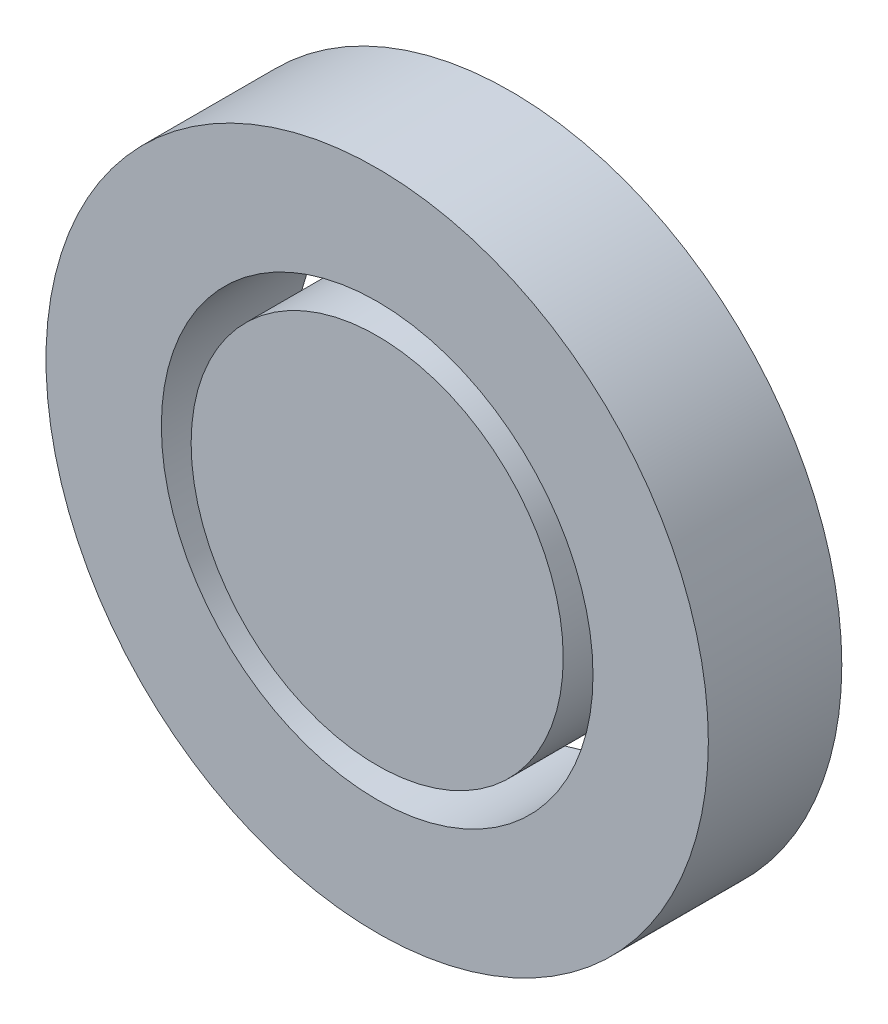
from build123d import *

# Parameters (mm, degrees)
SKETCH1_R           = 75
BOSS_EXTRUDE1_DEPTH = 53.8
SKETCH1_3_R         = 133.5
SKETCH1_3_R_2       = 87
BOSS_EXTRUDE2_DEPTH = 53.8


with BuildPart() as part:
    # Sketch1 → Boss-Extrude1 (new body)
    with BuildSketch(Plane.XY):
        Circle(SKETCH1_R)
    extrude(amount=BOSS_EXTRUDE1_DEPTH)


with BuildPart() as body_2:
    # Sketch1_3 → Boss-Extrude2 (new body)
    with BuildSketch(Plane.XY):
        Circle(SKETCH1_3_R)
        Circle(SKETCH1_3_R_2, mode=Mode.SUBTRACT)
    extrude(amount=BOSS_EXTRUDE2_DEPTH)


solid = Compound([part.part, body_2.part])
